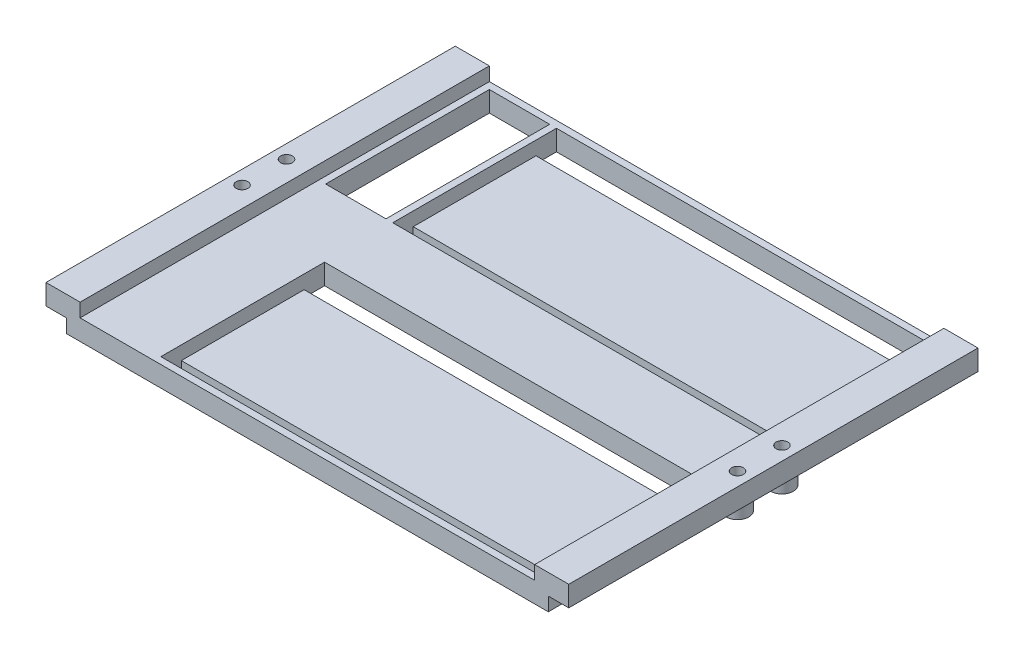
from build123d import *

# Parameters (mm, degrees)
PLATEFRAME_DEPTH          = 150
SKETCH3_R                 = 2.15
HOLESUPPORT_DEPTH         = 7.5
SKETCH4_R                 = 4.15
SKETCH4_R_2               = 2.15
CYLINDRICALSUPPORTS_DEPTH = 12.5
SKETCH8_W                 = 137
SKETCH8_H                 = 60
ITEMLAYOUT_DEPTH          = 5
SKETCH9_W                 = 137
SKETCH9_H                 = 7.5
VELCROHOLES_DEPTH         = 3.5
SKETCH10_W                = 22.1
SKETCH10_H                = 60
OPENHOLE_DEPTH            = 8.5


with BuildPart() as part:
    # Sketch2 → PlateFrame (new body)
    with BuildSketch(Plane.XY):
        Polygon((179.1, 12.5), (191.6, 12.5), (191.6, 5), (184.1, 5), (184.1, 0), (7.5, 0), (7.5, 5), (0, 5), (0, 12.5), (12.5, 12.5), (12.5, 7.5), (179.1, 7.5), align=None)
    extrude(amount=PLATEFRAME_DEPTH)

    # Sketch3 → HoleSupport (cut)
    with BuildSketch(Plane(origin=(0, 12.5, 0), x_dir=(1, 0, 0), z_dir=(0, 1, 0))):
        with Locations((5, -66.85)):
            Circle(SKETCH3_R)
        with Locations((5, -83.15)):
            Circle(SKETCH3_R)
        with Locations((186.6, -66.85)):
            Circle(SKETCH3_R)
        with Locations((186.6, -83.15)):
            Circle(SKETCH3_R)
    extrude(amount=-HOLESUPPORT_DEPTH, mode=Mode.SUBTRACT)

    # Sketch4 → CylindricalSupports (add)
    with BuildSketch(Plane(origin=(0, 12.5, 0), x_dir=(1, 0, 0), z_dir=(0, 1, 0))):
        with Locations((186.6, -66.85)):
            Circle(SKETCH4_R)
        with Locations((186.6, -66.85)):
            Circle(SKETCH4_R_2, mode=Mode.SUBTRACT)
        with Locations((186.6, -83.15)):
            Circle(SKETCH4_R)
        with Locations((186.6, -83.15)):
            Circle(SKETCH4_R_2, mode=Mode.SUBTRACT)
        with Locations((5, -66.85)):
            Circle(SKETCH4_R)
        with Locations((5, -66.85)):
            Circle(SKETCH4_R_2, mode=Mode.SUBTRACT)
        with Locations((5, -83.15)):
            Circle(SKETCH4_R)
        with Locations((5, -83.15)):
            Circle(SKETCH4_R_2, mode=Mode.SUBTRACT)
    extrude(amount=-CYLINDRICALSUPPORTS_DEPTH)

    # Sketch8 → ItemLayout (cut)
    with BuildSketch(Plane(origin=(0, 7.5, 0), x_dir=(1, 0, 0), z_dir=(0, 1, 0))):
        with Locations((108.1, -32.5)):
            Rectangle(SKETCH8_W, SKETCH8_H)
        with Locations((108.1, -117.5)):
            Rectangle(SKETCH8_W, SKETCH8_H)
    extrude(amount=-ITEMLAYOUT_DEPTH, mode=Mode.SUBTRACT)

    # Sketch9 → VelcroHoles (cut, through all)
    with BuildSketch(Plane(origin=(0, 2.5, 0), x_dir=(1, 0, 0), z_dir=(0, 1, 0))):
        with Locations((108.1, -143.75)):
            Rectangle(SKETCH9_W, SKETCH9_H)
        with Locations((108.1, -6.25)):
            Rectangle(SKETCH9_W, SKETCH9_H)
        with Locations((108.1, -91.25)):
            Rectangle(SKETCH9_W, SKETCH9_H)
        with Locations((108.1, -58.75)):
            Rectangle(SKETCH9_W, SKETCH9_H)
    extrude(amount=-VELCROHOLES_DEPTH, mode=Mode.SUBTRACT)

    # Sketch10 → OpenHole (cut, through all)
    with BuildSketch(Plane(origin=(0, 7.5, 0), x_dir=(1, 0, 0), z_dir=(0, 1, 0))):
        with Locations((26.05, -32.5)):
            Rectangle(SKETCH10_W, SKETCH10_H)
    extrude(amount=-OPENHOLE_DEPTH, mode=Mode.SUBTRACT)


solid = part.part
